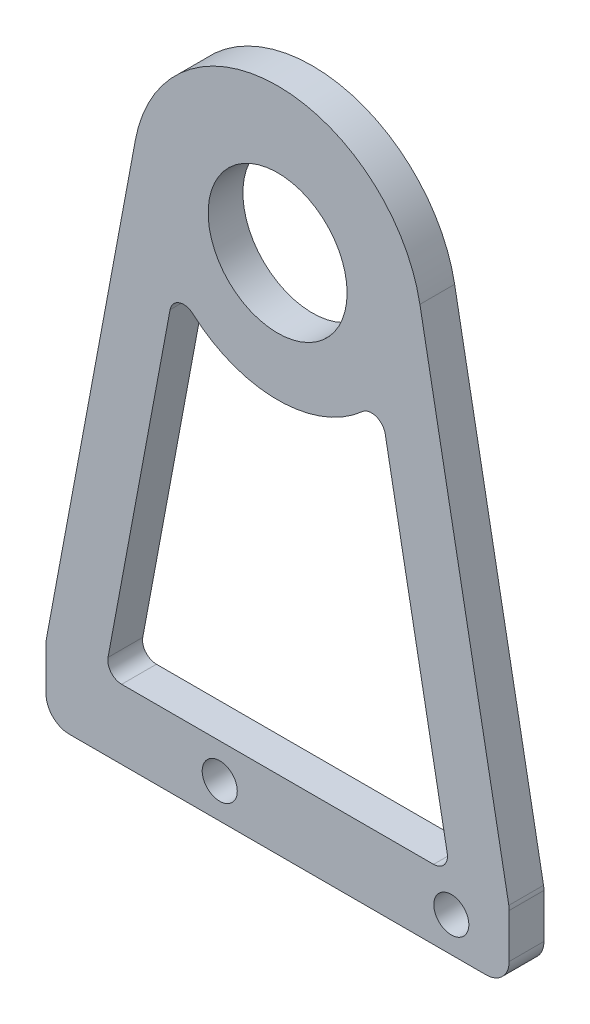
from build123d import *

# Parameters (mm, degrees)
SKETCH_1_R          = 6
EXTRUDE_1_DEPTH     = 3
FILLET_1_R          = 2
SKETCH_2_R          = 1.515
CUT_EXTRUDE_1_DEPTH = 10
CUT_EXTRUDE_2_DEPTH = 10
FILLET_2_R          = 1.2


with BuildPart() as part:
    # 草图1 → 凸台-拉伸1 (new body)
    with BuildSketch(Plane.XY):
        with BuildLine():
            Line((-20, -45), (20, -45))
            Line((20, -45), (20, -39))
            Line((20, -39), (12.287533689, 2.294889071))
            ThreePointArc((12.287533689, 2.294889071), (0, 12.5), (-12.287533689, 2.294889071))
            Line((-12.287533689, 2.294889071), (-20, -39))
            Line((-20, -39), (-20, -45))
        make_face()
        Circle(SKETCH_1_R, mode=Mode.SUBTRACT)
    extrude(amount=EXTRUDE_1_DEPTH)

    # 圆角1
    fillet_1_edges = [part.edges().sort_by_distance(p)[0] for p in [
        (20, -39, 1.5),
        (20, -45, 1.5),
        (-20, -45, 1.5),
        (-20, -39, 1.5),
    ]]
    fillet(fillet_1_edges, radius=FILLET_1_R)

    # 草图2 → 切除-拉伸1 (cut)
    with BuildSketch(Plane.XY.offset(3)):
        with Locations((-5, -42)):
            Circle(SKETCH_2_R)
        with Locations((15, -42)):
            Circle(SKETCH_2_R)
    extrude(amount=-CUT_EXTRUDE_1_DEPTH, mode=Mode.SUBTRACT)

    # 草图3 → 切除-拉伸2 (cut)
    with BuildSketch(Plane.XY.offset(3)):
        with BuildLine():
            Line((-8.849829987, -6.53303216), (-14.913543956, -39))
            Line((-14.913543956, -39), (14.913543956, -39))
            Line((14.913543956, -39), (8.849829987, -6.53303216))
            ThreePointArc((8.849829987, -6.53303216), (0, -11), (-8.849829987, -6.53303216))
        make_face()
    extrude(amount=-CUT_EXTRUDE_2_DEPTH, mode=Mode.SUBTRACT)

    # 圆角2
    fillet_2_edges = [part.edges().sort_by_distance(p)[0] for p in [
        (-8.849829987, -6.53303216, 1.5),
        (8.849829987, -6.53303216, 1.5),
        (14.913543956, -39, 1.5),
        (-14.913543956, -39, 1.5),
    ]]
    fillet(fillet_2_edges, radius=FILLET_2_R)


solid = part.part
